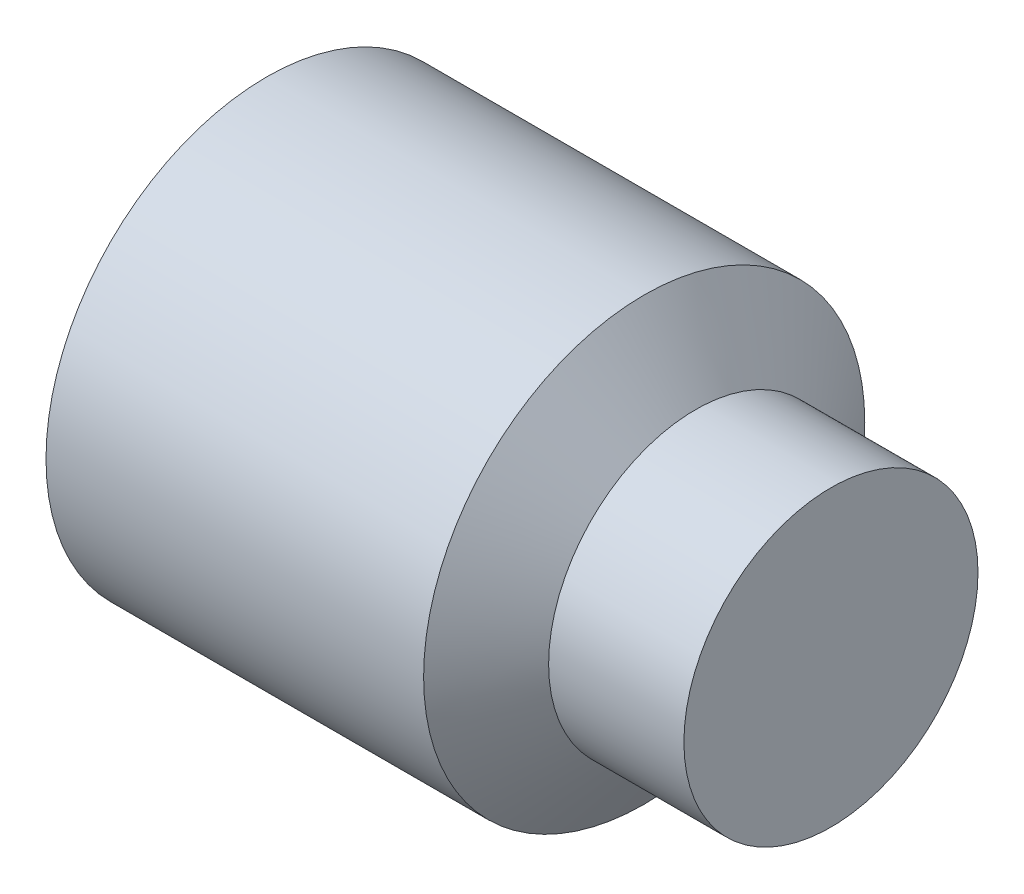
from build123d import *

# Parameters (mm, degrees)
HEX_2_DEPTH = 2


with BuildPart() as part:
    # BodySke → BaseBody (revolve)
    with BuildSketch(Plane.XY):
        Polygon((0, 0), (0, 1.2195), (0.161946751, 1.5), (2.729896231, 1.5), (3.08, 1), (4, 1), (4, 0), align=None)
    revolve(axis=Axis((-12.7, 0, 0), (1, 0, 0)))

    # Sketch2 → Hex 2 (cut)
    with BuildSketch(Plane.ZY):
        Polygon((0.433012702, 0.75), (-0.433012702, 0.75), (-0.866025404, 0), (-0.433012702, -0.75), (0.433012702, -0.75), (0.866025404, 0), align=None)
    extrude(amount=-HEX_2_DEPTH, mode=Mode.SUBTRACT)


solid = part.part
